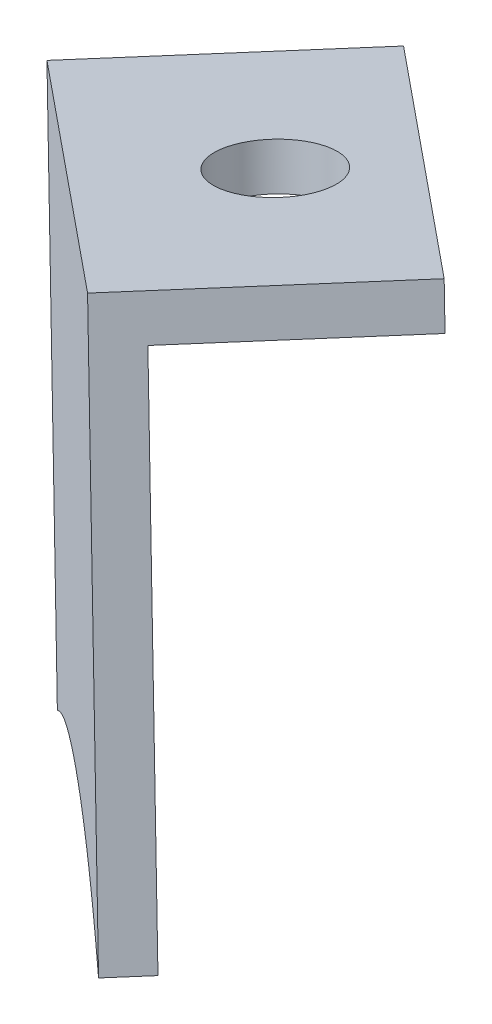
from build123d import *

# Parameters (mm, degrees)
DODANIE_WYCI_GNI_CIE1_DEPTH       = 2
WYCI_GNI_CIE_CIENKA_CIANKA1_DEPTH = 10
SZKIC3_R                          = 2.5
WYTNIJ_WYCI_GNI_CIE1_DEPTH        = 10


with BuildPart() as part:
    # Szkic1 → Dodanie-wyciągnięcie1 (new body)
    with BuildSketch(Plane(origin=(184.050171811, 0, -211.725502995), x_dir=(-0.75470958, 0, -0.656059029), z_dir=(0.656059029, 0, -0.75470958))):
        with BuildLine():
            Line((-985.697252828, -340.259541181), (-980.419174897, -315.823054253))
            Line((-980.419174897, -315.823054253), (-960.869985355, -320.045516598))
            Line((-960.869985355, -320.045516598), (-965.879501286, -343.238613058))
            add(Edge.make_bspline(
                [(-985.697252828, -340.259541181), (-980.093985624, -337.678026431), (-972.488962975, -338.490376385), (-965.879501286, -343.238613058)],
                knots=[0.113652907, 0.113652907, 0.113652907, 0.113652907, 0.285976573, 0.285976573, 0.285976573, 0.285976573], degree=3, weights=[0.648724237, 0.52341314, 0.477289897, 0.510354511]))
        make_face()
    extrude(amount=DODANIE_WYCI_GNI_CIE1_DEPTH)

    # Szkic2 → Wyciągnięcie-cienka ścianka1 (add)
    with BuildSketch(Plane(origin=(185.362289869, 0, -213.234922155), x_dir=(-0.75470958, 0, -0.656059029), z_dir=(0.656059029, 0, -0.75470958))):
        Polygon((-980.419174897, -315.823054253), (-960.869985355, -320.045516598), (-961.292231589, -322.000435553), (-980.841421131, -317.777973208), align=None)
    extrude(amount=WYCI_GNI_CIE_CIENKA_CIANKA1_DEPTH)

    # Szkic3 → Wytnij-wyciągnięcie1 (cut)
    with BuildSketch(Plane(origin=(82.487524873, -506.024310162, 71.705311407), x_dir=(-0.987224309, -0.157760609, 0.022355198), z_dir=(0.159336639, -0.977459477, 0.138509227))):
        with Locations((-849.886383223, -371.032714173)):
            Circle(SZKIC3_R)
    extrude(amount=-WYTNIJ_WYCI_GNI_CIE1_DEPTH, mode=Mode.SUBTRACT)


solid = part.part
